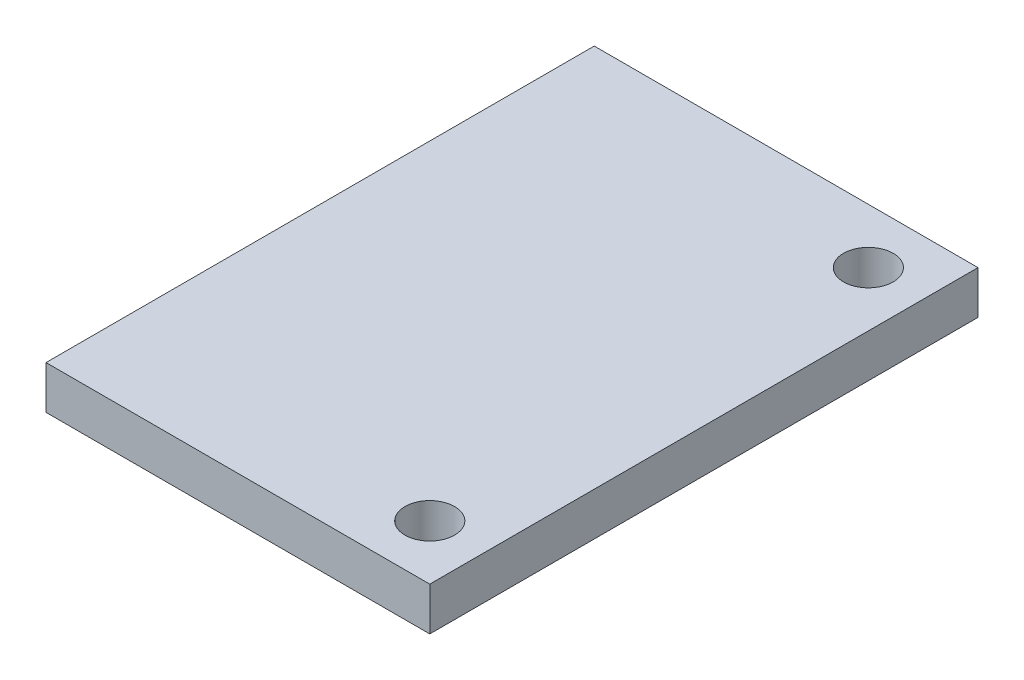
from build123d import *

# Parameters (mm, degrees)
SKETCH2_W           = 17.78
SKETCH2_H           = 25.4
BOSS_EXTRUDE1_DEPTH = 2
SKETCH3_R           = 1.15
CUT_EXTRUDE1_DEPTH  = 2


with BuildPart() as part:
    # Sketch2 → Boss-Extrude1 (new body)
    with BuildSketch(Plane(origin=(0, 0, 0), x_dir=(1, 0, 0), z_dir=(0, 1, 0))):
        Rectangle(SKETCH2_W, SKETCH2_H)
    extrude(amount=BOSS_EXTRUDE1_DEPTH)

    # Sketch3 → Cut-Extrude1 (cut)
    with BuildSketch(Plane(origin=(0, 2, 0), x_dir=(1, 0, 0), z_dir=(0, 1, 0))):
        with Locations((6.35, 10.16)):
            Circle(SKETCH3_R)
        with Locations((6.35, -10.16)):
            Circle(SKETCH3_R)
    extrude(amount=-CUT_EXTRUDE1_DEPTH, mode=Mode.SUBTRACT)


solid = part.part
